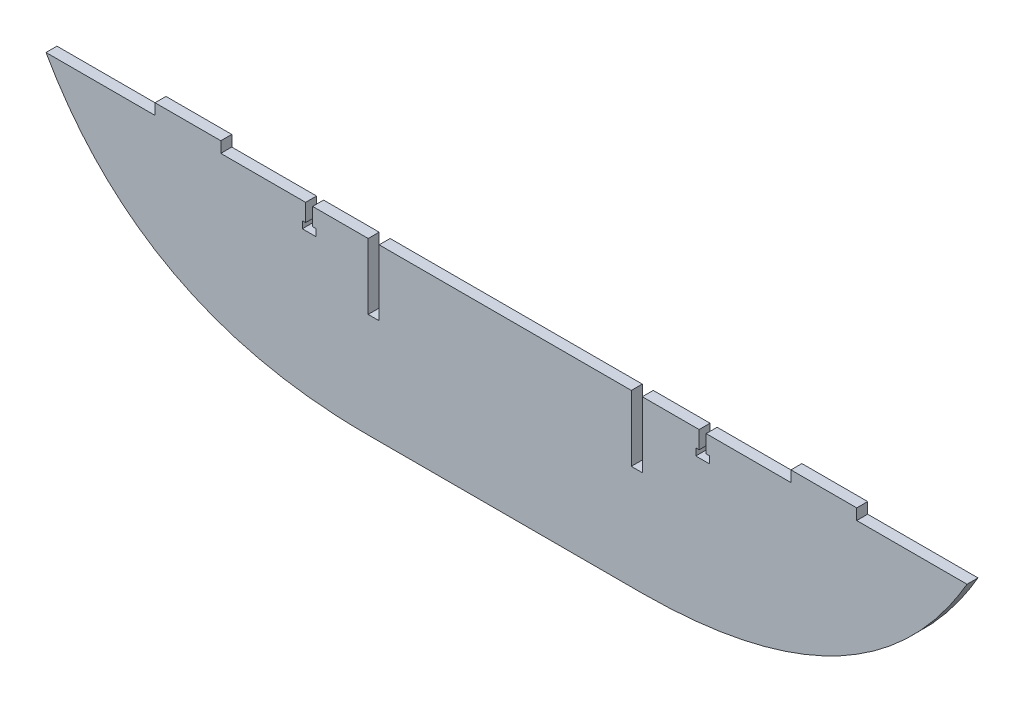
from build123d import *

# Parameters (mm, degrees)
BOSS_EXTRUDE13_DEPTH = 6.35


with BuildPart() as part:
    # Sketch1 → Boss-Extrude13 (new body)
    with BuildSketch(Plane.XY):
        with BuildLine():
            Line((-193.675, 406.4), (-130.538105188, 406.4))
            Line((-130.538105188, 406.4), (-130.538105188, 412.75))
            Line((-130.538105188, 412.75), (-92.438105188, 412.75))
            Line((-92.438105188, 412.75), (-92.438105188, 406.4))
            Line((-92.438105188, 406.4), (-43.316932521, 406.4))
            Line((-43.316932521, 406.4), (-43.316932521, 396.24))
            Line((-43.316932521, 396.24), (-45.221932521, 396.24))
            Line((-45.221932521, 396.24), (-45.221932521, 392.176))
            Line((-45.221932521, 392.176), (-37.347932521, 392.176))
            Line((-37.347932521, 392.176), (-37.347932521, 396.24))
            Line((-37.347932521, 396.24), (-39.252932521, 396.24))
            Line((-39.252932521, 396.24), (-39.252932521, 406.4))
            Line((-39.252932521, 406.4), (-7.076210377, 406.4))
            Line((-7.076210377, 406.4), (-7.076210377, 368.3))
            Line((-7.076210377, 368.3), (-6.35, 368.3))
            Line((-6.35, 368.3), (-0.726210377, 368.3))
            Line((-0.726210377, 368.3), (-0.726210377, 406.4))
            Line((-0.726210377, 406.4), (0, 406.4))
            Line((0, 406.4), (145.323789623, 406.4))
            Line((145.323789623, 406.4), (145.323789623, 368.3))
            Line((145.323789623, 368.3), (151.673789623, 368.3))
            Line((151.673789623, 368.3), (151.673789623, 406.4))
            Line((151.673789623, 406.4), (152.4, 406.4))
            Line((152.4, 406.4), (184.576722144, 406.4))
            Line((184.576722144, 406.4), (184.576722144, 396.24))
            Line((184.576722144, 396.24), (182.671722144, 396.24))
            Line((182.671722144, 396.24), (182.671722144, 392.176))
            Line((182.671722144, 392.176), (190.545722144, 392.176))
            Line((190.545722144, 392.176), (190.545722144, 396.24))
            Line((190.545722144, 396.24), (188.640722144, 396.24))
            Line((188.640722144, 396.24), (188.640722144, 406.4))
            Line((188.640722144, 406.4), (237.761894812, 406.4))
            Line((237.761894812, 406.4), (237.761894812, 412.75))
            Line((237.761894812, 412.75), (275.861894812, 412.75))
            Line((275.861894812, 412.75), (275.861894812, 406.4))
            Line((275.861894812, 406.4), (339.75144841, 406.4))
            add(Edge.make_bspline(
                [(152.4, 307.792730185), (282.8477338, 308.473912291), (339.75144841, 406.4)],
                knots=[0, 0, 0, 1, 1, 1], degree=2))
            Line((152.4, 307.792730185), (-6.35, 307.792730185))
            add(Edge.make_bspline(
                [(-193.675, 406.4), (-138.010339731, 307.440275388), (-6.35, 307.792730185)],
                knots=[0, 0, 0, 1, 1, 1], degree=2))
        make_face()
    extrude(amount=BOSS_EXTRUDE13_DEPTH)


solid = part.part
